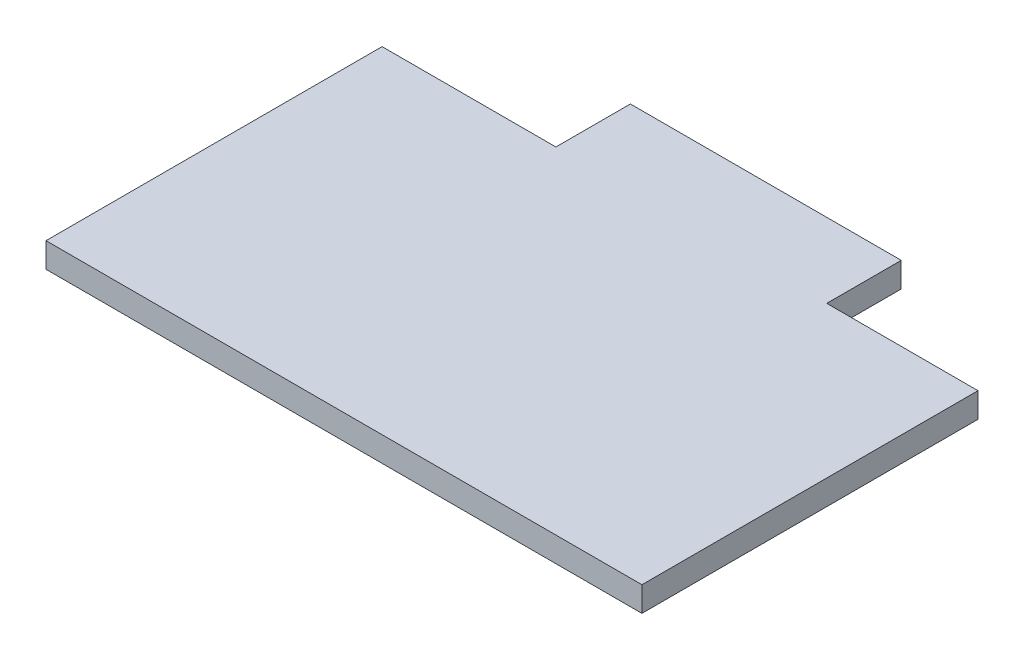
from build123d import *

# Parameters (mm, degrees)
SKETCH1_W           = 304.8
SKETCH1_H           = 210
BOSS_EXTRUDE1_DEPTH = 12.7
SKETCH2_W           = 103.826139809
SKETCH2_H           = 75.404069631
SKETCH2_W_2         = 105.873975136
CUT_EXTRUDE1_DEPTH  = 121


with BuildPart() as part:
    # Sketch1 → Boss-Extrude1 (new body)
    with BuildSketch(Plane(origin=(0, 0, 0), x_dir=(1, 0, 0), z_dir=(0, 1, 0))):
        Rectangle(SKETCH1_W, SKETCH1_H)
    extrude(amount=BOSS_EXTRUDE1_DEPTH)

    # Sketch2 → Cut-Extrude1 (cut)
    with BuildSketch(Plane.XZ):
        with Locations((-115.413069905, -104.602034816)):
            Rectangle(SKETCH2_W, SKETCH2_H)
        with Locations((127.97392141, -104.602034816)):
            Rectangle(SKETCH2_W_2, SKETCH2_H)
    extrude(amount=-CUT_EXTRUDE1_DEPTH, mode=Mode.SUBTRACT)


solid = part.part
